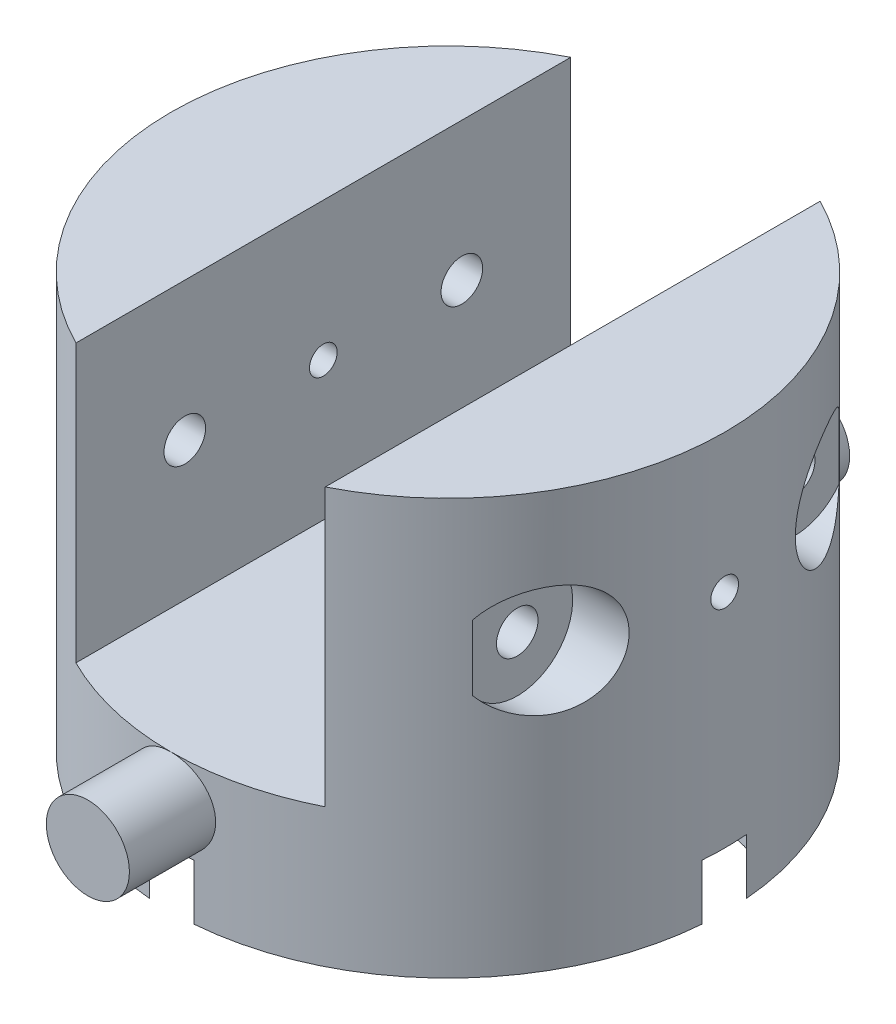
from build123d import *

# Parameters (mm, degrees)
SKETCH1_R                      = 10
SKETCH1_R_2                    = 2.5
BOSS_EXTRUDE1_DEPTH            = 5
BOSS_EXTRUDE4_DEPTH            = 10
SKETCH6_R                      = 0.75
CUT_EXTRUDE3_DEPTH             = 21
SKETCH7_R                      = 2
CUT_EXTRUDE4_DEPTH             = 2.5
SKETCH8_R                      = 2
CUT_EXTRUDE5_DEPTH             = 2.5
BOSS_EXTRUDE5_START            = -7.5
SKETCH10_R                     = 1.5
BOSS_EXTRUDE5_DEPTH            = 10.5
CUT_EXTRUDE6_REACH             = 12
SKETCH11_R                     = 0.5
CUT_EXTRUDE6_DIRECTION_2_REACH = 12
SKETCH12_R                     = 2.5
CUT_EXTRUDE7_DEPTH             = 2
CIRPATTERN1_COUNT              = 4
SKETCH13_R                     = 5.4
SKETCH13_R_2                   = 4.15
CUT_EXTRUDE8_DEPTH             = 2


with BuildPart() as part:
    # Sketch1 → Boss-Extrude1 (new body)
    with BuildSketch(Plane(origin=(0, 0, 0), x_dir=(1, 0, 0), z_dir=(0, 1, 0))):
        Circle(SKETCH1_R)
        Circle(SKETCH1_R_2, mode=Mode.SUBTRACT)
    extrude(amount=BOSS_EXTRUDE1_DEPTH)

    # Sketch5 → Boss-Extrude4 (add)
    with BuildSketch(Plane(origin=(0, 5, 0), x_dir=(1, 0, 0), z_dir=(0, 1, 0))):
        with BuildLine():
            Line((4.5, 8.93028555), (4.5, -8.93028555))
            ThreePointArc((4.5, -8.93028555), (10, 0), (4.5, 8.93028555))
        make_face()
        with BuildLine():
            Line((-4.5, 8.93028555), (-4.5, -8.93028555))
            ThreePointArc((-4.5, -8.93028555), (-10, 0), (-4.5, 8.93028555))
        make_face()
    extrude(amount=BOSS_EXTRUDE4_DEPTH)

    # Sketch6 → Cut-Extrude3 (cut, through all)
    with BuildSketch(Plane.ZY.offset(10)):
        with Locations((-5, 10)):
            Circle(SKETCH6_R)
        with Locations((5, 10)):
            Circle(SKETCH6_R)
    extrude(amount=-CUT_EXTRUDE3_DEPTH, mode=Mode.SUBTRACT)

    # Sketch7 → Cut-Extrude4 (cut)
    with BuildSketch(Plane.ZY.offset(10)):
        with Locations((-5, 10)):
            Circle(SKETCH7_R)
        with Locations((5, 10)):
            Circle(SKETCH7_R)
    extrude(amount=-CUT_EXTRUDE4_DEPTH, mode=Mode.SUBTRACT)

    # Sketch8 → Cut-Extrude5 (cut)
    with BuildSketch(Plane(origin=(10, 0, 0), x_dir=(0, 0, -1), z_dir=(1, 0, 0))):
        with Locations((-5, 10)):
            Circle(SKETCH8_R)
        with Locations((5, 10)):
            Circle(SKETCH8_R)
    extrude(amount=-CUT_EXTRUDE5_DEPTH, mode=Mode.SUBTRACT)

    # Sketch10 → Boss-Extrude5 (add)
    with BuildSketch(Plane.XY.offset(10).offset(BOSS_EXTRUDE5_START)):
        with Locations((0, 3.5)):
            Circle(SKETCH10_R)
    boss_extrude5 = extrude(amount=BOSS_EXTRUDE5_DEPTH)

    # Mirror1: Boss-Extrude5 across plane
    add(boss_extrude5.mirror(Plane.XY))

    # Sketch11 → Cut-Extrude6 (cut, up to next)
    with BuildSketch(Plane(origin=(0, 0, 0), x_dir=(0, 0, -1), z_dir=(1, 0, 0)), mode=Mode.PRIVATE) as cut_extrude6_sk1:
        with Locations((0, 10)):
            Circle(SKETCH11_R)
    cut_extrude6_tool1 = extrude(cut_extrude6_sk1.sketch, amount=-CUT_EXTRUDE6_REACH, mode=Mode.PRIVATE) & part.part
    add(cut_extrude6_tool1.solids().sort_by_distance((0, 10, 0))[0], mode=Mode.SUBTRACT)

    # Sketch11 → Cut-Extrude6 direction 2 (cut, up to next)
    with BuildSketch(Plane(origin=(0, 0, 0), x_dir=(0, 0, -1), z_dir=(1, 0, 0)), mode=Mode.PRIVATE) as cut_extrude6_direction_2_sk1:
        with Locations((0, 10)):
            Circle(SKETCH11_R)
    cut_extrude6_direction_2_tool1 = extrude(cut_extrude6_direction_2_sk1.sketch, amount=CUT_EXTRUDE6_DIRECTION_2_REACH, mode=Mode.PRIVATE) & part.part
    add(cut_extrude6_direction_2_tool1.solids().sort_by_distance((0, 10, 0))[0], mode=Mode.SUBTRACT)

    # Sketch12 → Cut-Extrude7 (cut)
    with BuildSketch(Plane.XZ):
        with Locations((-7.6, 0)):
            Circle(SKETCH12_R)
    cut_extrude7 = extrude(amount=-CUT_EXTRUDE7_DEPTH, mode=Mode.SUBTRACT)

    # CirPattern1: Cut-Extrude7 ×4 about axis
    cirpattern1_axis = Axis((0, 0, 0), (0, 1, 0))
    for i in range(1, CIRPATTERN1_COUNT):
        add(cut_extrude7.rotate(cirpattern1_axis, i * 360 / CIRPATTERN1_COUNT), mode=Mode.SUBTRACT)

    # Sketch13 → Cut-Extrude8 (cut)
    with BuildSketch(Plane.XZ):
        Circle(SKETCH13_R)
        Circle(SKETCH13_R_2, mode=Mode.SUBTRACT)
    extrude(amount=-CUT_EXTRUDE8_DEPTH, mode=Mode.SUBTRACT)


solid = part.part
